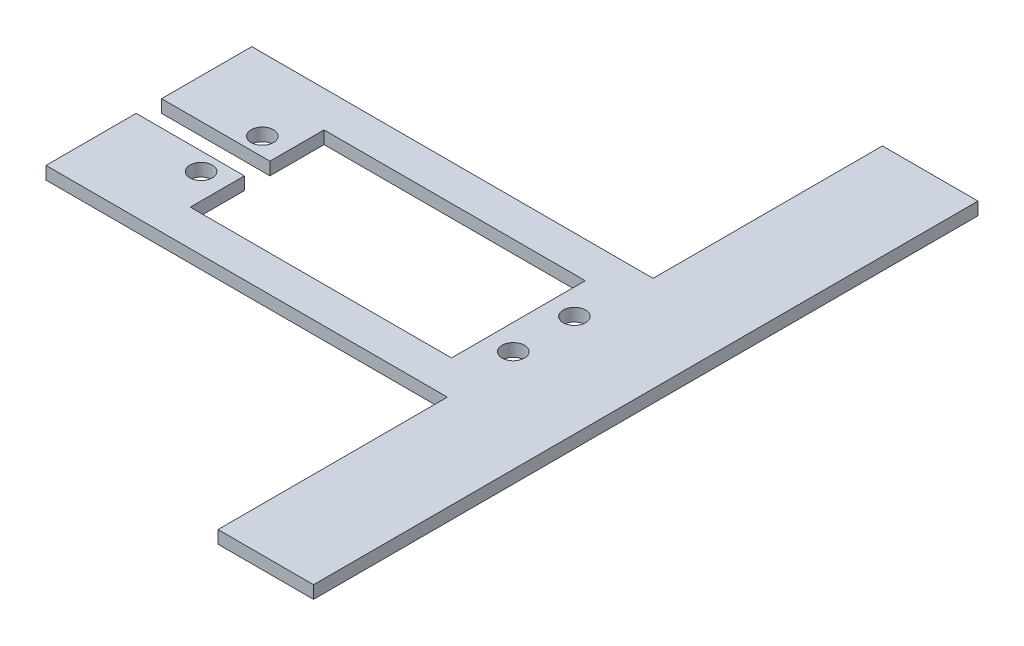
from build123d import *

# Parameters (mm, degrees)
SKETCH1_R           = 1.75
BOSS_EXTRUDE1_DEPTH = 2


with BuildPart() as part:
    # Sketch1 → Boss-Extrude1 (new body)
    with BuildSketch(Plane(origin=(0, 0, 0), x_dir=(1, 0, 0), z_dir=(0, 1, 0))):
        Polygon((-37.5, 16.15), (25.5, 16.15), (25.5, 52.15), (40.5, 52.15), (40.5, -52.15), (25.5, -52.15), (25.5, -16.15), (-37.5, -16.15), (-37.5, -2), (-20.5, -2), (-20.5, -10.5), (20.5, -10.5), (20.5, 10.5), (-20.5, 10.5), (-20.5, 2), (-37.5, 2), align=None)
        with Locations((-24.5, 4.8)):
            Circle(SKETCH1_R, mode=Mode.SUBTRACT)
        with Locations((-24.5, -4.8)):
            Circle(SKETCH1_R, mode=Mode.SUBTRACT)
        with Locations((24.5, -4.8)):
            Circle(SKETCH1_R, mode=Mode.SUBTRACT)
        with Locations((24.5, 4.8)):
            Circle(SKETCH1_R, mode=Mode.SUBTRACT)
    extrude(amount=BOSS_EXTRUDE1_DEPTH)


solid = part.part
